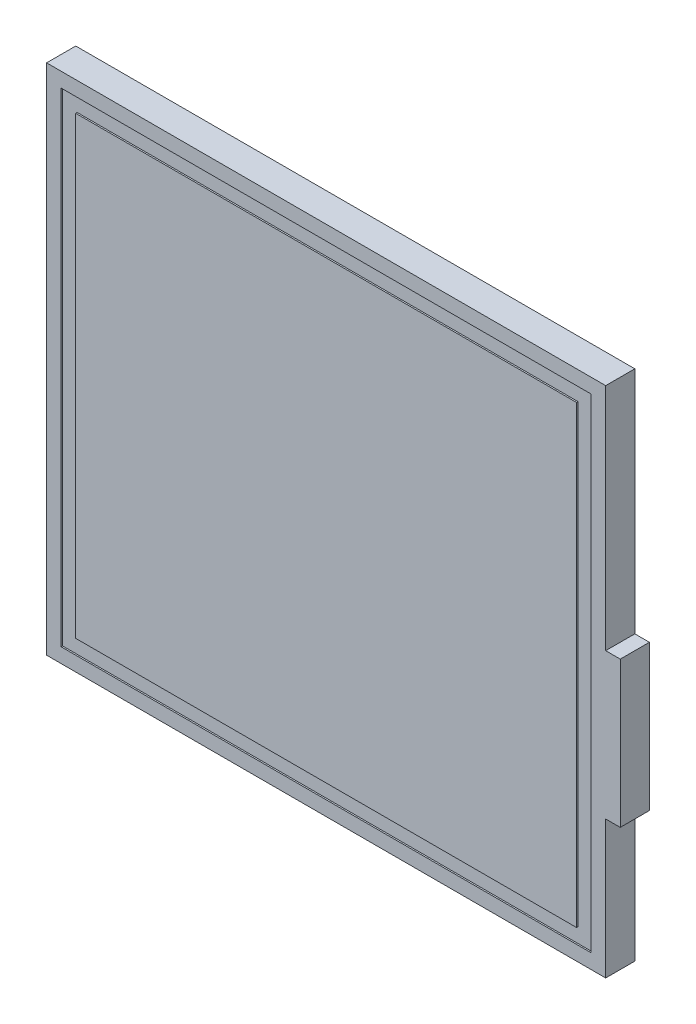
from build123d import *

# Parameters (mm, degrees)
EXTRUDE1_DEPTH     = 5
CUT_EXTRUDE1_DEPTH = 3
SKETCH1_W          = 36.36
SKETCH1_H          = 33.2
SKETCH1_W_2        = 34.36
SKETCH1_H_2        = 31.2
CUT_EXTRUDE2_DEPTH = 0.1


with BuildPart() as part:
    # COMPONENT_OUTLINE → Extrude1 (new body)
    with BuildSketch(Plane.XY):
        Polygon((19.18, -24.5), (20.18, -24.5), (20.18, -14.5), (19.18, -14.5), (19.18, 1.25), (-19.18, 1.25), (-19.18, -33.95), (19.18, -33.95), align=None)
    extrude(amount=EXTRUDE1_DEPTH)

    # Sketch2 → Cut-Extrude1 (cut)
    with BuildSketch(Plane(origin=(0, 0, 0), x_dir=(-1, 0, 0), z_dir=(0, 0, -1))):
        Polygon((-19.18, -24.5), (-19.18, -33.95), (19.18, -33.95), (19.18, 1.25), (-19.18, 1.25), (-19.18, -14.5), (-20.18, -14.5), (-20.18, -24.5), align=None)
        Polygon((-16.18, -21.5), (-16.18, -30.95), (16.18, -30.95), (16.18, -1.75), (-16.18, -1.75), (-16.18, -17.5), (-17.18, -17.5), (-17.18, -21.5), align=None, mode=Mode.SUBTRACT)
    extrude(amount=-CUT_EXTRUDE1_DEPTH, mode=Mode.SUBTRACT)

    # Sketch1 → Cut-Extrude2 (cut)
    with BuildSketch(Plane.XY.offset(5)):
        with Locations((0, -16.35)):
            Rectangle(SKETCH1_W, SKETCH1_H)
        with Locations((0, -16.35)):
            Rectangle(SKETCH1_W_2, SKETCH1_H_2, mode=Mode.SUBTRACT)
    extrude(amount=-CUT_EXTRUDE2_DEPTH, mode=Mode.SUBTRACT)


solid = part.part
